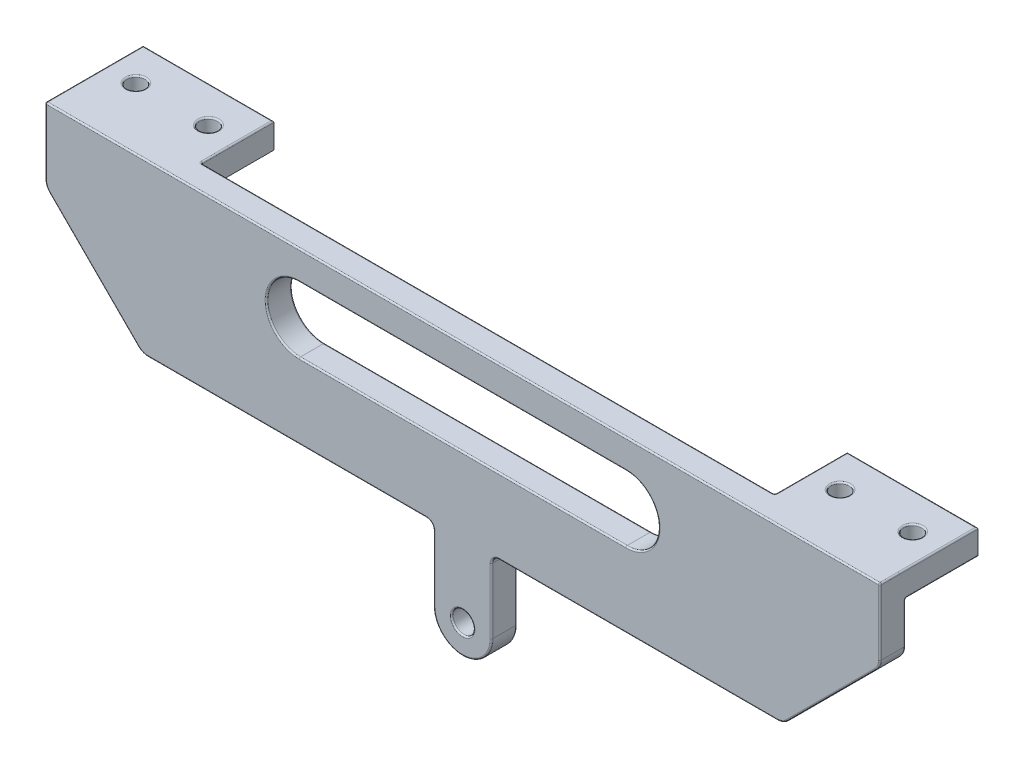
from build123d import *

# Parameters (mm, degrees)
SKETCH5_R           = 1.5
BOSS_EXTRUDE1_DEPTH = 3.5
SKETCH6_W           = 18
SKETCH6_H           = 10
SKETCH6_R           = 1.25
BOSS_EXTRUDE2_DEPTH = 3.5
FILLET1_R           = 2
FILLET2_R           = 1
FILLET3_R           = 0.2


with BuildPart() as part:
    # Sketch5 → Boss-Extrude1 (new body)
    with BuildSketch(Plane.XY):
        with BuildLine():
            Line((57.5, 93.357864376), (-57.5, 93.357864376))
            Line((-57.5, 93.357864376), (-57.5, 83.357864376))
            Line((-57.5, 83.357864376), (-44.142135624, 70))
            Line((-44.142135624, 70), (-4, 70))
            Line((-4, 70), (-4, 60))
            ThreePointArc((-4, 60), (0, 56), (4, 60))
            Line((4, 60), (4, 70))
            Line((4, 70), (44.142135624, 70))
            Line((44.142135624, 70), (57.5, 83.357864376))
            Line((57.5, 83.357864376), (57.5, 93.357864376))
        make_face()
        with Locations((0, 60)):
            Circle(SKETCH5_R, mode=Mode.SUBTRACT)
        with BuildLine():
            Line((-22.5, 80.357864376), (22.5, 80.357864376))
            ThreePointArc((22.5, 80.357864376), (27, 84.857864376), (22.5, 89.357864376))
            Line((22.5, 89.357864376), (-22.5, 89.357864376))
            ThreePointArc((-22.5, 89.357864376), (-27, 84.857864376), (-22.5, 80.357864376))
        make_face(mode=Mode.SUBTRACT)
    extrude(amount=BOSS_EXTRUDE1_DEPTH)

    # Sketch6 → Boss-Extrude2 (add)
    with BuildSketch(Plane(origin=(0, 93.357864376, 0), x_dir=(1, 0, 0), z_dir=(0, 1, 0))):
        with Locations((-48.5, 5)):
            Rectangle(SKETCH6_W, SKETCH6_H)
        with Locations((-43.5, 5)):
            Circle(SKETCH6_R, mode=Mode.SUBTRACT)
        with Locations((-53.5, 5)):
            Circle(SKETCH6_R, mode=Mode.SUBTRACT)
        with Locations((48.5, 5)):
            Rectangle(SKETCH6_W, SKETCH6_H)
        with Locations((53.5, 5)):
            Circle(SKETCH6_R, mode=Mode.SUBTRACT)
        with Locations((43.5, 5)):
            Circle(SKETCH6_R, mode=Mode.SUBTRACT)
    extrude(amount=-BOSS_EXTRUDE2_DEPTH)

    # Fillet1
    fillet1_edges = [part.edges().sort_by_distance(p)[0] for p in [
        (57.5, 83.357864376, 1.75),
        (44.142135624, 70, 1.75),
        (-44.142135624, 70, 1.75),
        (-57.5, 83.357864376, 1.75),
    ]]
    fillet(fillet1_edges, radius=FILLET1_R)

    # Fillet2
    fillet2_edges = [part.edges().sort_by_distance(p)[0] for p in [
        (4, 70, 1.75),
        (-4, 70, 1.75),
    ]]
    fillet(fillet2_edges, radius=FILLET2_R)

    # Fillet3
    fillet3_edges = [part.edges().sort_by_distance(p)[0] for p in [
        (24.156854249, 70, 0),
        (24.156854249, 70, 3.5),
        (-4, 64.5, 0),
        (-4, 64.5, 3.5),
        (4.292893219, 69.707106781, 0),
        (4.292893219, 69.707106781, 3.5),
        (-4.292893219, 69.707106781, 0),
        (-4.292893219, 69.707106781, 3.5),
        (4, 64.5, 0),
        (0, 56, 0),
        (0, 56, 3.5),
        (-57.5, 93.357864376, -3.25),
        (57.5, 93.357864376, -3.25),
        (4, 64.5, 3.5),
        (-1.5, 60, 0),
        (-1.5, 60, 3.5),
        (0, 93.357864376, 3.5),
        (27, 84.857864376, 0),
        (0, 89.357864376, 0),
        (-27, 84.857864376, 0),
        (0, 80.357864376, 0),
        (27, 84.857864376, 3.5),
        (0, 89.357864376, 3.5),
        (-27, 84.857864376, 3.5),
        (0, 80.357864376, 3.5),
        (-57.5, 88.772077939, 3.5),
        (-57.5, 87.022077939, 0),
        (-57.5, 89.857864376, -5),
        (-48.5, 89.857864376, 0),
        (-39.5, 91.607864376, 0),
        (-39.5, 93.357864376, -5),
        (-48.5, 93.357864376, -10),
        (-44.75, 93.357864376, -5),
        (-54.75, 93.357864376, -5),
        (0, 93.357864376, 0),
        (48.5, 89.857864376, 0),
        (39.5, 91.607864376, 0),
        (57.5, 89.857864376, -5),
        (48.5, 93.357864376, -10),
        (39.5, 93.357864376, -5),
        (52.25, 93.357864376, -5),
        (42.25, 93.357864376, -5),
        (57.5, 87.022077939, 0),
        (57.5, 88.772077939, 3.5),
        (50.821067812, 76.678932188, 0),
        (-24.156854249, 70, 0),
        (-50.821067812, 76.678932188, 0),
        (-57.347759065, 83.420924636, 0),
        (-44.079075364, 70.152240935, 0),
        (44.079075364, 70.152240935, 0),
        (57.347759065, 83.420924636, 0),
        (50.821067812, 76.678932188, 3.5),
        (-50.821067812, 76.678932188, 3.5),
        (-24.156854249, 70, 3.5),
        (-57.347759065, 83.420924636, 3.5),
        (-44.079075364, 70.152240935, 3.5),
        (44.079075364, 70.152240935, 3.5),
        (57.347759065, 83.420924636, 3.5),
    ]]
    fillet(fillet3_edges, radius=FILLET3_R)


solid = part.part
